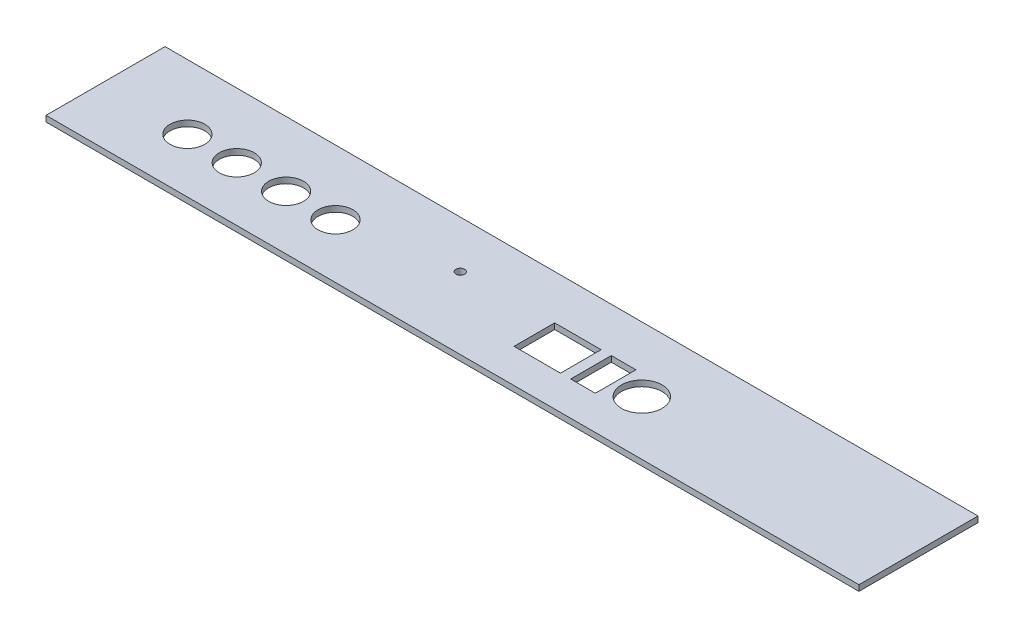
from build123d import *

# Parameters (mm, degrees)
SKETCH_1_W      = 280
SKETCH_1_H      = 41
SKETCH_1_R      = 6
SKETCH_1_R_2    = 7
SKETCH_1_R_3    = 1.5
SKETCH_1_W_2    = 16
SKETCH_1_H_2    = 14
SKETCH_1_W_3    = 8.5
EXTRUDE_1_DEPTH = 2


with BuildPart() as part:
    # 草图1 → 凸台-拉伸1 (new body)
    with BuildSketch(Plane(origin=(0, 0, 0), x_dir=(1, 0, 0), z_dir=(0, 1, 0))):
        with Locations((140, 20.5)):
            Rectangle(SKETCH_1_W, SKETCH_1_H)
        with Locations((30, 18.7)):
            Circle(SKETCH_1_R, mode=Mode.SUBTRACT)
        with Locations((47, 18.7)):
            Circle(SKETCH_1_R, mode=Mode.SUBTRACT)
        with Locations((64, 18.7)):
            Circle(SKETCH_1_R, mode=Mode.SUBTRACT)
        with Locations((81, 18.7)):
            Circle(SKETCH_1_R, mode=Mode.SUBTRACT)
        with Locations((186.5, 18.7)):
            Circle(SKETCH_1_R_2, mode=Mode.SUBTRACT)
        with Locations((118, 24.7)):
            Circle(SKETCH_1_R_3, mode=Mode.SUBTRACT)
        with Locations((157.5, 18.7)):
            Rectangle(SKETCH_1_W_2, SKETCH_1_H_2, mode=Mode.SUBTRACT)
        with Locations((173.25, 18.7)):
            Rectangle(SKETCH_1_W_3, SKETCH_1_H_2, mode=Mode.SUBTRACT)
    extrude(amount=EXTRUDE_1_DEPTH)


solid = part.part
